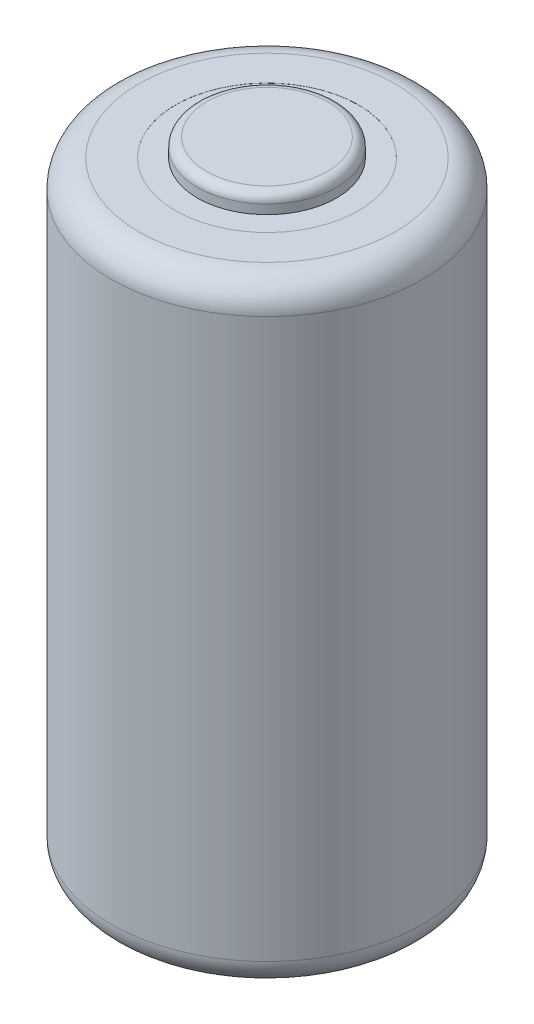
from build123d import *

# Parameters (mm, degrees)
SKIZZE1_R                       = 8.5
AUFSATZ_LINEAR_AUSTRAGEN1_DEPTH = 33.5
SKIZZE2_R                       = 3.799988553
AUFSATZ_LINEAR_AUSTRAGEN2_DEPTH = 1
VERRUNDUNG1_R                   = 1.5
VERRUNDUNG2_R                   = 0.5
SKIZZE3_R                       = 5
SKIZZE3_R_2                     = 3.799988553
SCHNITT_LINEAR_AUSTRAGEN1_DEPTH = 0.005


with BuildPart() as part:
    # Skizze1 → Aufsatz-Linear austragen1 (new body)
    with BuildSketch(Plane(origin=(0, 0, 0), x_dir=(1, 0, 0), z_dir=(0, 1, 0))):
        Circle(SKIZZE1_R)
    extrude(amount=AUFSATZ_LINEAR_AUSTRAGEN1_DEPTH)

    # Skizze2 → Aufsatz-Linear austragen2 (add)
    with BuildSketch(Plane(origin=(0, 33.5, 0), x_dir=(1, 0, 0), z_dir=(0, 1, 0))):
        Circle(SKIZZE2_R)
    extrude(amount=AUFSATZ_LINEAR_AUSTRAGEN2_DEPTH)

    # Verrundung1
    verrundung1_edges = [part.edges().sort_by_distance(p)[0] for p in [
        (-8.5, 0, 0),
        (-8.5, 33.5, 0),
    ]]
    fillet(verrundung1_edges, radius=VERRUNDUNG1_R)

    # Verrundung2
    verrundung2_edges = [part.edges().sort_by_distance(p)[0] for p in [
        (-3.799988553, 34.5, 0),
    ]]
    fillet(verrundung2_edges, radius=VERRUNDUNG2_R)

    # Skizze3 → Schnitt-Linear austragen1 (cut)
    with BuildSketch(Plane(origin=(0, 33.5, 0), x_dir=(1, 0, 0), z_dir=(0, 1, 0))):
        Circle(SKIZZE3_R)
        Circle(SKIZZE3_R_2, mode=Mode.SUBTRACT)
    extrude(amount=-SCHNITT_LINEAR_AUSTRAGEN1_DEPTH, mode=Mode.SUBTRACT)


solid = part.part
